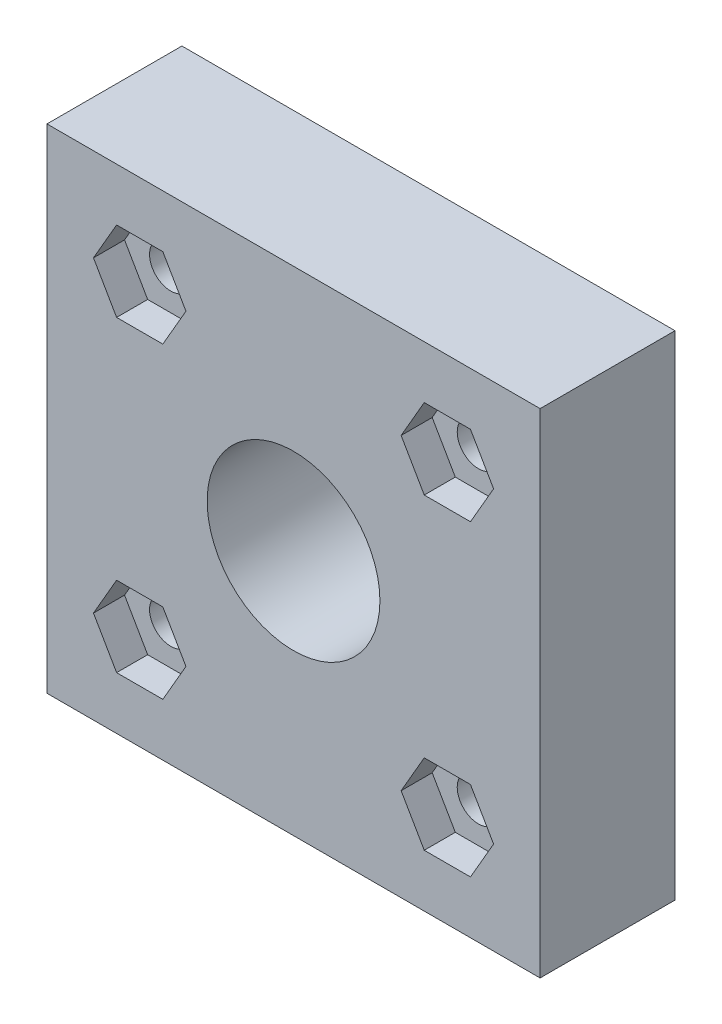
from build123d import *

# Parameters (mm, degrees)
SKETCH1_W           = 25.4
SKETCH1_H           = 25.4
BOSS_EXTRUDE1_DEPTH = 1.6
SKETCH2_R           = 4.45
CUT_EXTRUDE1_DEPTH  = 19.031638861
CUT_EXTRUDE2_DEPTH  = 19.031638861
SKETCH4_W           = 25.4
SKETCH4_H           = 25.4
SKETCH4_R           = 1.0922
SKETCH4_R_2         = 4.45
BOSS_EXTRUDE2_DEPTH = 5.35


with BuildPart() as part:
    # Sketch1 → Boss-Extrude1 (new body)
    with BuildSketch(Plane.XY):
        Rectangle(SKETCH1_W, SKETCH1_H)
    extrude(amount=BOSS_EXTRUDE1_DEPTH)

    # Sketch2 → Cut-Extrude1 (cut, through all)
    with BuildSketch(Plane.XY.offset(1.6)):
        Circle(SKETCH2_R)
    extrude(amount=-CUT_EXTRUDE1_DEPTH, mode=Mode.SUBTRACT)

    # Sketch3 → Cut-Extrude2 (cut, through all)
    with BuildSketch(Plane.XY.offset(1.6)):
        Polygon((9.113937588, 5.861089595), (6.732687588, 5.861089595), (5.542062588, 7.923312588), (6.732687588, 9.985535581), (9.113937588, 9.985535581), (10.304562588, 7.923312588), align=None)
        Polygon((-6.732687588, 5.861089595), (-5.542062588, 7.923312588), (-6.732687588, 9.985535581), (-9.113937588, 9.985535581), (-10.304562588, 7.923312588), (-9.113937588, 5.861089595), align=None)
        Polygon((6.732687588, -5.861089595), (5.542062588, -7.923312588), (6.732687588, -9.985535581), (9.113937588, -9.985535581), (10.304562588, -7.923312588), (9.113937588, -5.861089595), align=None)
        Polygon((-9.113937588, -5.861089595), (-6.732687588, -5.861089595), (-5.542062588, -7.923312588), (-6.732687588, -9.985535581), (-9.113937588, -9.985535581), (-10.304562588, -7.923312588), align=None)
    extrude(amount=-CUT_EXTRUDE2_DEPTH, mode=Mode.SUBTRACT)

    # Sketch4 → Boss-Extrude2 (add)
    with BuildSketch(Plane(origin=(0, 0, 0), x_dir=(-1, 0, 0), z_dir=(0, 0, -1))):
        Rectangle(SKETCH4_W, SKETCH4_H)
        with Locations((7.923312588, -7.923312588)):
            Circle(SKETCH4_R, mode=Mode.SUBTRACT)
        with Locations((-7.923312588, -7.923312588)):
            Circle(SKETCH4_R, mode=Mode.SUBTRACT)
        with Locations((7.923312588, 7.923312588)):
            Circle(SKETCH4_R, mode=Mode.SUBTRACT)
        with Locations((-7.923312588, 7.923312588)):
            Circle(SKETCH4_R, mode=Mode.SUBTRACT)
        with Locations(Location((0, 0, 0), (0, 0, 180))):
            Circle(SKETCH4_R_2, mode=Mode.SUBTRACT)
    extrude(amount=BOSS_EXTRUDE2_DEPTH)


solid = part.part
